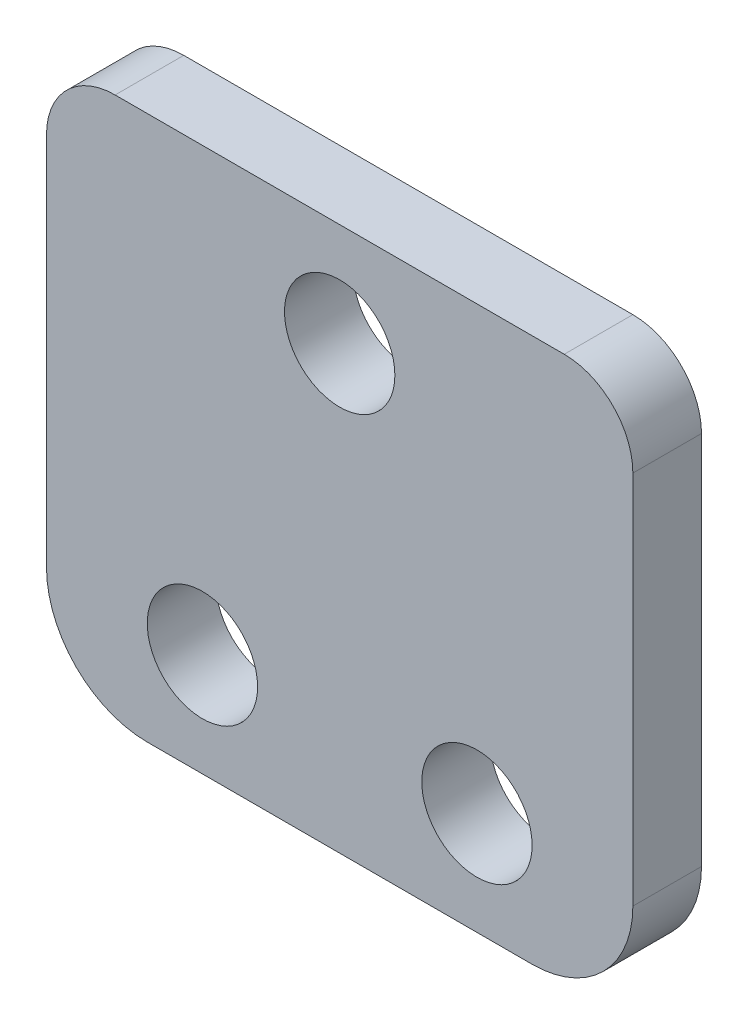
from build123d import *

# Parameters (mm, degrees)
BOSS_EXTRUDE1_DEPTH    = 3.175
F_10_CLEARANCE_HOLE1_D = 5.1054


with BuildPart() as part:
    # Sketch1 → Boss-Extrude1 (new body)
    with BuildSketch(Plane.XY):
        with BuildLine():
            Line((-8.9027, 4.6609), (8.9027, 4.6609))
            ThreePointArc((8.9027, 4.6609), (12.198453996, 3.295753996), (13.5636, 0))
            Line((13.5636, 0), (13.5636, 17.3482))
            ThreePointArc((13.5636, 17.3482), (12.63366403, 19.59326403), (10.3886, 20.5232))
            Line((10.3886, 20.5232), (-10.3886, 20.5232))
            ThreePointArc((-10.3886, 20.5232), (-12.63366403, 19.59326403), (-13.5636, 17.3482))
            Line((-13.5636, 17.3482), (-13.5636, 0))
            ThreePointArc((-13.5636, 0), (-12.198453996, 3.295753996), (-8.9027, 4.6609))
        make_face()
        with BuildLine():
            ThreePointArc((13.5636, 0), (12.198453996, 3.295753996), (8.9027, 4.6609))
            Line((8.9027, 4.6609), (-8.9027, 4.6609))
            ThreePointArc((-8.9027, 4.6609), (-12.198453996, 3.295753996), (-13.5636, 0))
            ThreePointArc((-13.5636, 0), (-12.198453996, -3.295753996), (-8.9027, -4.6609))
            Line((-8.9027, -4.6609), (8.9027, -4.6609))
            ThreePointArc((8.9027, -4.6609), (12.198453996, -3.295753996), (13.5636, 0))
        make_face()
    extrude(amount=BOSS_EXTRUDE1_DEPTH)

    # #10 Clearance Hole1 (through all)
    with Locations(Plane.XY.offset(3.175)):
        with Locations((6.35, 0.1016), (-6.35, 0.1016), (0, 15.7607)):
            Hole(F_10_CLEARANCE_HOLE1_D / 2)


solid = part.part
